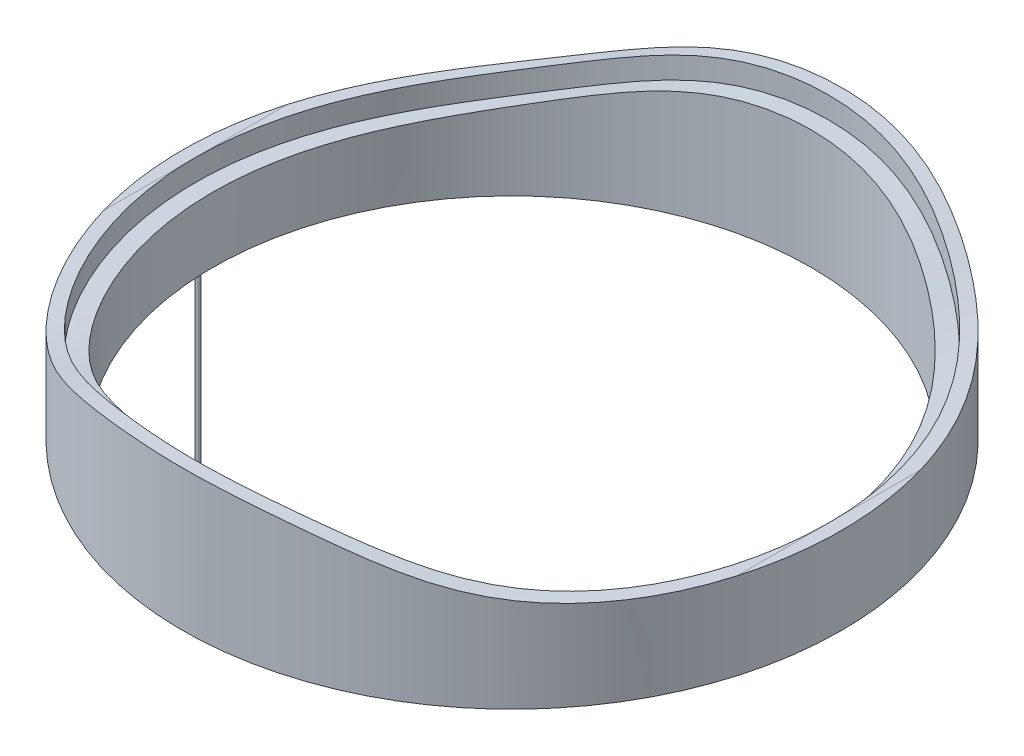
from build123d import *

# Parameters (mm, degrees)
SKETCH1_R           = 73.1
SKETCH1_R_2         = 69.1
EXTRUDE_THIN1_DEPTH = 30
CUT_EXTRUDE1_DEPTH  = 75
SKETCH3_R           = 76.1
SKETCH3_R_2         = 73.1
EXTRUDE_THIN2_DEPTH = 50
CUT_EXTRUDE2_DEPTH  = 77.5
SKETCH5_R           = 0.5
BOSS_EXTRUDE1_DEPTH = 50


with BuildPart() as part:
    # Sketch1 → Extrude-Thin1 (new body)
    with BuildSketch(Plane(origin=(0, 0, 0), x_dir=(1, 0, 0), z_dir=(0, 1, 0))):
        Circle(SKETCH1_R)
        Circle(SKETCH1_R_2, mode=Mode.SUBTRACT)
    extrude(amount=EXTRUDE_THIN1_DEPTH)

    # Sketch2 → Cut-Extrude1 (cut, symmetric)
    with BuildSketch(Plane.XY):
        with BuildLine():
            Line((-73.1, 15), (-73.1, 30))
            Line((-73.1, 30), (0, 30))
            Line((0, 30), (73.1, 30))
            Line((73.1, 30), (73.1, 15))
            add(Edge.make_bspline(
                [(-73.1, 15), (-43.1, 15), (-36.023333333, 27.604166667), (36.023333333, 27.604166667), (43.1, 15), (73.1, 15)],
                knots=[0, 0, 0, 0, 0.45, 0.55, 1, 1, 1, 1], degree=3))
        make_face()
    extrude(amount=CUT_EXTRUDE1_DEPTH, both=True, mode=Mode.SUBTRACT)

    # Sketch3 → Extrude-Thin2 (add)
    with BuildSketch(Plane(origin=(0, 0, 0), x_dir=(1, 0, 0), z_dir=(0, 1, 0))):
        Circle(SKETCH3_R)
        Circle(SKETCH3_R_2, mode=Mode.SUBTRACT)
    extrude(amount=EXTRUDE_THIN2_DEPTH)

    # Sketch4 → Cut-Extrude2 (cut, symmetric)
    with BuildSketch(Plane.XY):
        with BuildLine():
            Line((-73.1, 20), (-76.1, 20))
            Line((-76.1, 20), (-76.1, 50))
            Line((-76.1, 50), (76.1, 50))
            Line((76.1, 50), (76.1, 20))
            Line((76.1, 20), (73.1, 20))
            add(Edge.make_bspline(
                [(-73.1, 20), (-43.1, 20), (-36.023333333, 32.604166667), (36.023333333, 32.604166667), (43.1, 20), (73.1, 20)],
                knots=[0, 0, 0, 0, 0.45, 0.55, 1, 1, 1, 1], degree=3))
        make_face()
    extrude(amount=CUT_EXTRUDE2_DEPTH, both=True, mode=Mode.SUBTRACT)

    # Sketch5 → Boss-Extrude1 (add)
    with BuildSketch(Plane.XZ):
        with Locations((-72.5, 0)):
            Circle(SKETCH5_R)
    extrude(amount=BOSS_EXTRUDE1_DEPTH)


solid = part.part
